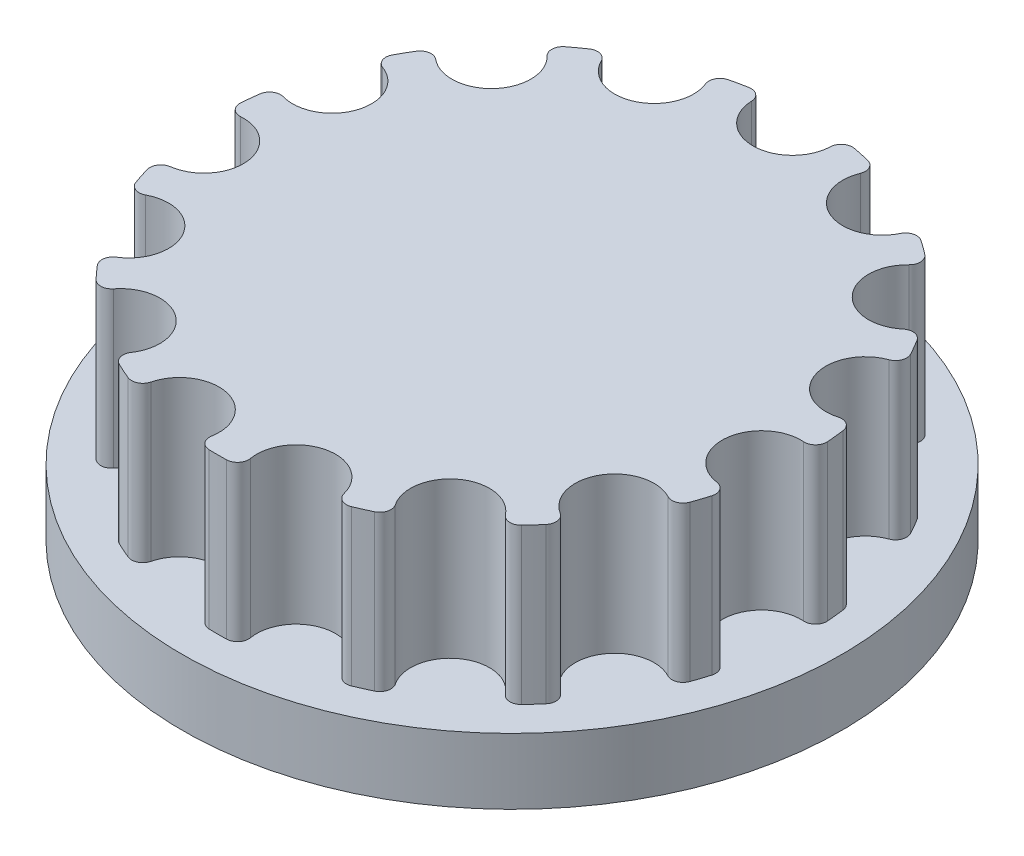
from build123d import *

# Parameters (mm, degrees)
BOSS_EXTRUDE1_DEPTH = 3
CIRPATTERN1_COUNT   = 15
SKETCH2_R           = 12.73044952
BOSS_EXTRUDE2_DEPTH = 2.54


with BuildPart() as part:
    # Sketch1 → Boss-Extrude1 (new, symmetric)
    with BuildSketch(Plane(origin=(0, 0, 0), x_dir=(1, 0, 0), z_dir=(0, 1, 0))):
        with BuildLine():
            ThreePointArc((0, 9.305199576), (1.058591657, 9.732470692), (1.52399559, 10.774860293))
            ThreePointArc((1.52399559, 10.774860293), (1.684189321, 11.094304623), (2.030537225, 11.182337802))
            ThreePointArc((2.030537225, 11.182337802), (2.362957849, 11.116842642), (2.693278481, 11.041467799))
            ThreePointArc((2.693278481, 11.041467799), (2.973876716, 10.820173105), (2.990291257, 10.463189528))
            ThreePointArc((2.990291257, 10.463189528), (2.991480859, 9.321622409), (3.784765639, 8.500722805))
            ThreePointArc((3.784765639, 8.500722805), (-1.934659777, -9.10185864), (0, 9.305199576))
        make_face()
    boss_extrude1 = extrude(amount=BOSS_EXTRUDE1_DEPTH, both=True)

    # CirPattern1: Boss-Extrude1 ×15 about axis
    cirpattern1_axis = Axis((0, 3.3, 0), (0, -1, 0))
    for i in range(1, CIRPATTERN1_COUNT):
        add(boss_extrude1.rotate(cirpattern1_axis, i * 360 / CIRPATTERN1_COUNT))

    # Sketch2 → Boss-Extrude2 (add)
    with BuildSketch(Plane.XZ.offset(3)):
        Circle(SKETCH2_R)
    extrude(amount=BOSS_EXTRUDE2_DEPTH)


solid = part.part
